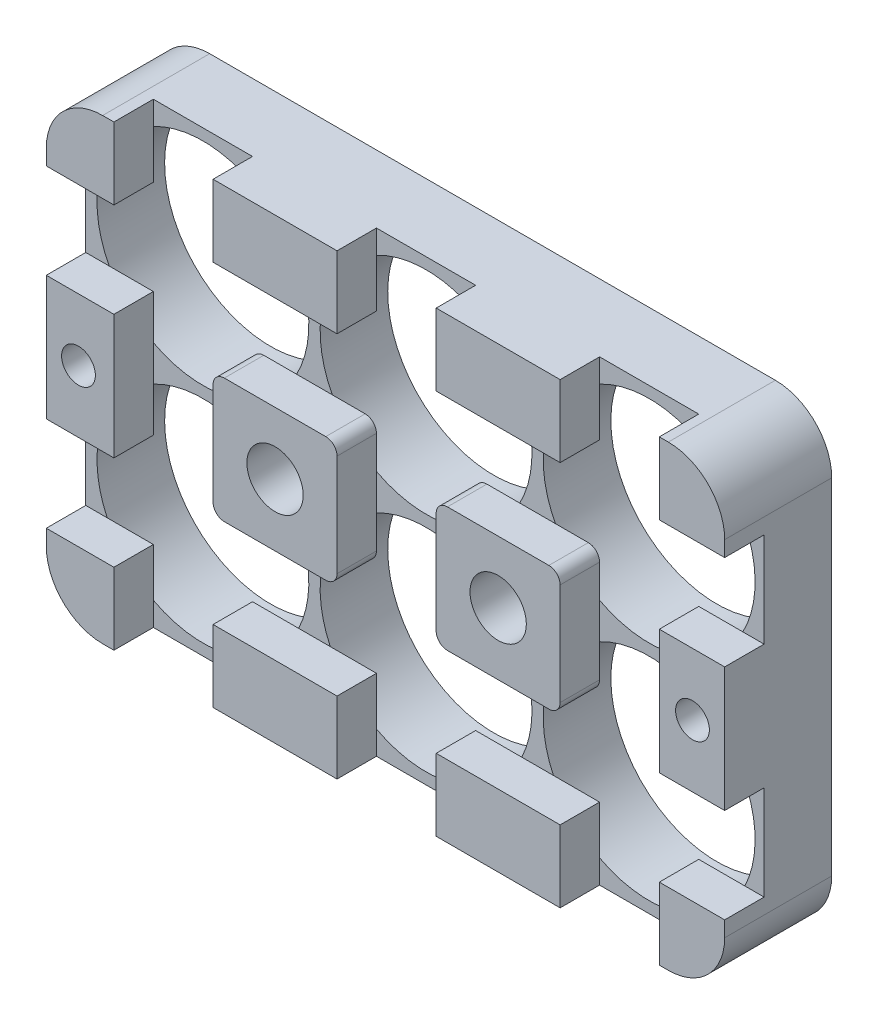
from build123d import *

# Parameters (mm, degrees)
SKETCH_1_W               = 60.2
SKETCH_1_H               = 40.6
SKETCH_1_R               = 9.4
SKETCH_1_R_2             = 2.5
EXTRUDE_1_DEPTH          = 6
SKETCH_2_W               = 60.2
SKETCH_2_H               = 40.6
EXTRUDE_2_DEPTH          = 3.5
SKETCH_3_W               = 60.2
SKETCH_3_H               = 8.4
CUT_EXTRUDE_1_DEPTH      = 3.5
SKETCH_4_W               = 8.8
SKETCH_4_H               = 40.6
CUT_EXTRUDE_2_DEPTH      = 3.5
SKETCH_5_R               = 2.5
SKETCH_5_R_2             = 1.5
CUT_EXTRUDE_3_DEPTH      = 10
CUT_EXTRUDE_3_DEPTH_BACK = 10
FILLET_3_R               = 5
FILLET_8_R               = 5
FILLET_9_R               = 5
FILLET_10_R              = 5
FILLET_11_R              = 1
FILLET_12_R              = 1
FILLET_13_R              = 1
FILLET_14_R              = 1
FILLET_15_R              = 1
FILLET_16_R              = 1
FILLET_17_R              = 1
FILLET_18_R              = 1


with BuildPart() as part:
    # 草图1 → 凸台-拉伸1 (new body)
    with BuildSketch(Plane.XY):
        with Locations((19.7, -9.9)):
            Rectangle(SKETCH_1_W, SKETCH_1_H)
        Circle(SKETCH_1_R, mode=Mode.SUBTRACT)
        with Locations((19.8, 0)):
            Circle(SKETCH_1_R, mode=Mode.SUBTRACT)
        with Locations((39.6, 0)):
            Circle(SKETCH_1_R, mode=Mode.SUBTRACT)
        with Locations((0, -19.8)):
            Circle(SKETCH_1_R, mode=Mode.SUBTRACT)
        with Locations((19.8, -19.8)):
            Circle(SKETCH_1_R, mode=Mode.SUBTRACT)
        with Locations((39.6, -19.8)):
            Circle(SKETCH_1_R, mode=Mode.SUBTRACT)
        with Locations((9.9, -9.9)):
            Circle(SKETCH_1_R_2, mode=Mode.SUBTRACT)
        with Locations((29.7, -9.9)):
            Circle(SKETCH_1_R_2, mode=Mode.SUBTRACT)
    extrude(amount=EXTRUDE_1_DEPTH)

    # 草图2 → 凸台-拉伸2 (add)
    with BuildSketch(Plane.XY.offset(6)):
        with Locations((19.7, -9.9)):
            Rectangle(SKETCH_2_W, SKETCH_2_H)
    extrude(amount=EXTRUDE_2_DEPTH)

    # 草图3 → 切除-拉伸1 (cut)
    with BuildSketch(Plane.XY.offset(9.5)):
        with Locations((19.7, -0.18)):
            Rectangle(SKETCH_3_W, SKETCH_3_H)
        with Locations((19.7, -19.62)):
            Rectangle(SKETCH_3_W, SKETCH_3_H)
    extrude(amount=-CUT_EXTRUDE_1_DEPTH, mode=Mode.SUBTRACT)

    # 草图4 → 切除-拉伸2 (cut)
    with BuildSketch(Plane.XY.offset(9.5)):
        with Locations((0, -9.9)):
            Rectangle(SKETCH_4_W, SKETCH_4_H)
        with Locations((19.8, -9.9)):
            Rectangle(SKETCH_4_W, SKETCH_4_H)
        with Locations((39.6, -9.9)):
            Rectangle(SKETCH_4_W, SKETCH_4_H)
        with Locations((59.4, -9.9)):
            Rectangle(SKETCH_4_W, SKETCH_4_H)
    extrude(amount=-CUT_EXTRUDE_2_DEPTH, mode=Mode.SUBTRACT)

    # 草图5 → 切除-拉伸3 (cut, two sides)
    with BuildSketch(Plane(origin=(0, 0, 6), x_dir=(-1, 0, 0), z_dir=(0, 0, -1))) as cut_extrude_3_sk:
        with Locations((-29.7, -9.9)):
            Circle(SKETCH_5_R)
        with Locations((-9.9, -9.9)):
            Circle(SKETCH_5_R)
        with Locations((-46.944325479, -9.9)):
            Circle(SKETCH_5_R_2)
        with Locations((7.544325479, -9.9)):
            Circle(SKETCH_5_R_2)
    extrude(amount=CUT_EXTRUDE_3_DEPTH, mode=Mode.SUBTRACT)
    extrude(cut_extrude_3_sk.sketch, amount=-CUT_EXTRUDE_3_DEPTH_BACK, mode=Mode.SUBTRACT)

    # 圆角3
    fillet_3_edges = [part.edges().sort_by_distance(p)[0] for p in [
        (-10.4, -30.2, 4.75),
    ]]
    fillet(fillet_3_edges, radius=FILLET_3_R)

    # 圆角8
    fillet_8_edges = [part.edges().sort_by_distance(p)[0] for p in [
        (49.8, -30.2, 4.75),
    ]]
    fillet(fillet_8_edges, radius=FILLET_8_R)

    # 圆角9
    fillet_9_edges = [part.edges().sort_by_distance(p)[0] for p in [
        (49.8, 10.4, 4.75),
    ]]
    fillet(fillet_9_edges, radius=FILLET_9_R)

    # 圆角10
    fillet_10_edges = [part.edges().sort_by_distance(p)[0] for p in [
        (-10.4, 10.4, 4.75),
    ]]
    fillet(fillet_10_edges, radius=FILLET_10_R)

    # 圆角11
    fillet_11_edges = [part.edges().sort_by_distance(p)[0] for p in [
        (4.4, -4.38, 7.75),
    ]]
    fillet(fillet_11_edges, radius=FILLET_11_R)

    # 圆角12
    fillet_12_edges = [part.edges().sort_by_distance(p)[0] for p in [
        (4.4, -15.42, 7.75),
    ]]
    fillet(fillet_12_edges, radius=FILLET_12_R)

    # 圆角13
    fillet_13_edges = [part.edges().sort_by_distance(p)[0] for p in [
        (15.4, -15.42, 7.75),
    ]]
    fillet(fillet_13_edges, radius=FILLET_13_R)

    # 圆角14
    fillet_14_edges = [part.edges().sort_by_distance(p)[0] for p in [
        (15.4, -4.38, 7.75),
    ]]
    fillet(fillet_14_edges, radius=FILLET_14_R)

    # 圆角15
    fillet_15_edges = [part.edges().sort_by_distance(p)[0] for p in [
        (24.2, -15.42, 7.75),
    ]]
    fillet(fillet_15_edges, radius=FILLET_15_R)

    # 圆角16
    fillet_16_edges = [part.edges().sort_by_distance(p)[0] for p in [
        (35.2, -15.42, 7.75),
    ]]
    fillet(fillet_16_edges, radius=FILLET_16_R)

    # 圆角17
    fillet_17_edges = [part.edges().sort_by_distance(p)[0] for p in [
        (35.2, -4.38, 7.75),
    ]]
    fillet(fillet_17_edges, radius=FILLET_17_R)

    # 圆角18
    fillet_18_edges = [part.edges().sort_by_distance(p)[0] for p in [
        (24.2, -4.38, 7.75),
    ]]
    fillet(fillet_18_edges, radius=FILLET_18_R)


solid = part.part
